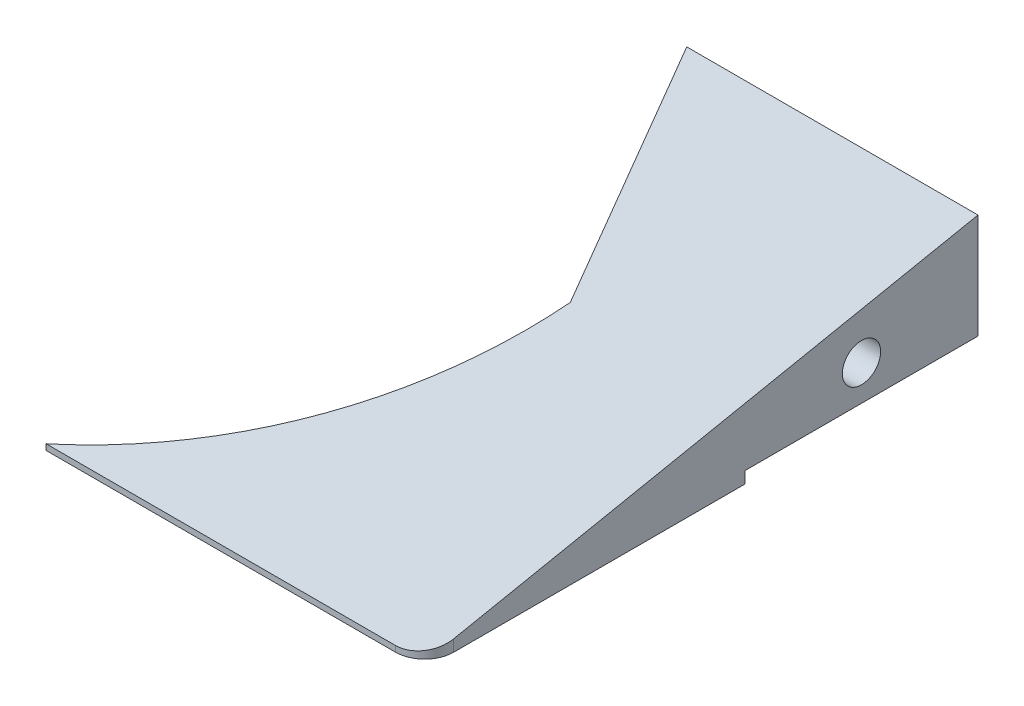
from build123d import *

# Parameters (mm, degrees)
ESBO_O1_W                                      = 130
ESBO_O1_H                                      = 20
RESSALTO_EXTRUS_O1_DEPTH                       = 95
CORTE_EXTRUS_O2_REACH                          = 22
CORTE_EXTRUS_O3_DEPTH                          = 1
CORTE_EXTRUS_O3_DEPTH_BACK                     = 66
BROCA_DE_ROSQUEAR_DE_CANO_PARA_TARRAXA_D_D     = 6.579997
BROCA_DE_ROSQUEAR_DE_CANO_PARA_TARRAXA_D_DEPTH = 10
BROCA_DE_ROSQUEAR_DE_CANO_PARA_TARRAXA_D_TIP   = 1.976830535
BROCA_DE_ROSQUEAR_DE_CANO_PARA_TARRA_2_D       = 6.579997
BROCA_DE_ROSQUEAR_DE_CANO_PARA_TARRA_2_DEPTH   = 10
BROCA_DE_ROSQUEAR_DE_CANO_PARA_TARRA_2_TIP     = 1.976830535
FILETE2_R                                      = 5
ESBO_O16_W                                     = 50
ESBO_O16_H                                     = 2
CORTE_EXTRUS_O6_DEPTH                          = 40


with BuildPart() as part:
    # Esboço1 → Ressalto-extrusão1 (new body)
    with BuildSketch(Plane.XY):
        Rectangle(ESBO_O1_W, ESBO_O1_H)
    extrude(amount=RESSALTO_EXTRUS_O1_DEPTH)

    # Esboço2 → Corte-extrusão2 (cut, up to next)
    with BuildSketch(Plane(origin=(0, 10, 0), x_dir=(1, 0, 0), z_dir=(0, 1, 0)), mode=Mode.PRIVATE) as corte_extrus_o2_sk1:
        with BuildLine():
            Line((15, 0), (-65, 0))
            Line((-65, 0), (-65, -95))
            Line((-65, -95), (0, -95))
            ThreePointArc((0, -95), (23.934348295, -71.594585279), (35, -40))
            Line((35, -40), (15, 0))
        make_face()
    corte_extrus_o2_tool1 = extrude(corte_extrus_o2_sk1.sketch, amount=-CORTE_EXTRUS_O2_REACH, mode=Mode.PRIVATE) & part.part
    add(corte_extrus_o2_tool1.solids().sort_by_distance((-20.013018, 10, 46.655676))[0], mode=Mode.SUBTRACT)

    # Esboço3 → Corte-extrusão3 (cut, two sides)
    with BuildSketch(Plane(origin=(65, 0, 0), x_dir=(0, 0, -1), z_dir=(1, 0, 0))) as corte_extrus_o3_sk:
        Polygon((200.200134404, 50.040026881), (0, 10), (-95, -9), (-295.200134404, -49.040026881), (-375.280188165, 351.360241926), (120.120080642, 450.440295688), align=None)
    extrude(amount=CORTE_EXTRUS_O3_DEPTH, mode=Mode.SUBTRACT)
    extrude(corte_extrus_o3_sk.sketch, amount=-CORTE_EXTRUS_O3_DEPTH_BACK, mode=Mode.SUBTRACT)

    # Broca de rosquear de cano para tarraxa d
    with Locations(Plane(origin=(65, 0, 0), x_dir=(0, 0, -1), z_dir=(1, 0, 0))):
        with Locations((-20, -1.945)):
            Hole(BROCA_DE_ROSQUEAR_DE_CANO_PARA_TARRAXA_D_D / 2, depth=BROCA_DE_ROSQUEAR_DE_CANO_PARA_TARRAXA_D_DEPTH)
            with Locations((0, 0, -(BROCA_DE_ROSQUEAR_DE_CANO_PARA_TARRAXA_D_DEPTH + BROCA_DE_ROSQUEAR_DE_CANO_PARA_TARRAXA_D_TIP / 2))):  # 118° drill point
                Cone(0, BROCA_DE_ROSQUEAR_DE_CANO_PARA_TARRAXA_D_D / 2, BROCA_DE_ROSQUEAR_DE_CANO_PARA_TARRAXA_D_TIP, mode=Mode.SUBTRACT)

    # Broca de rosquear de cano para tarra 2
    with Locations(Plane(origin=(12, 0, -6), x_dir=(0.447213595, 0, 0.894427191), z_dir=(-0.894427191, 0, 0.447213595))):
        with Locations((26.708203932, -1.945)):
            Hole(BROCA_DE_ROSQUEAR_DE_CANO_PARA_TARRA_2_D / 2, depth=BROCA_DE_ROSQUEAR_DE_CANO_PARA_TARRA_2_DEPTH)
            with Locations((0, 0, -(BROCA_DE_ROSQUEAR_DE_CANO_PARA_TARRA_2_DEPTH + BROCA_DE_ROSQUEAR_DE_CANO_PARA_TARRA_2_TIP / 2))):  # 118° drill point
                Cone(0, BROCA_DE_ROSQUEAR_DE_CANO_PARA_TARRA_2_D / 2, BROCA_DE_ROSQUEAR_DE_CANO_PARA_TARRA_2_TIP, mode=Mode.SUBTRACT)

    # Filete2
    filete2_edges = [part.edges().sort_by_distance(p)[0] for p in [
        (65, -9.5, 95),
    ]]
    fillet(filete2_edges, radius=FILETE2_R)

    # Esboço16 → Corte-extrusão6 (cut)
    with BuildSketch(Plane(origin=(0, 0, 0), x_dir=(-1, 0, 0), z_dir=(0, 0, -1))):
        with Locations((-40, -9)):
            Rectangle(ESBO_O16_W, ESBO_O16_H)
    extrude(amount=-CORTE_EXTRUS_O6_DEPTH, mode=Mode.SUBTRACT)


solid = part.part
